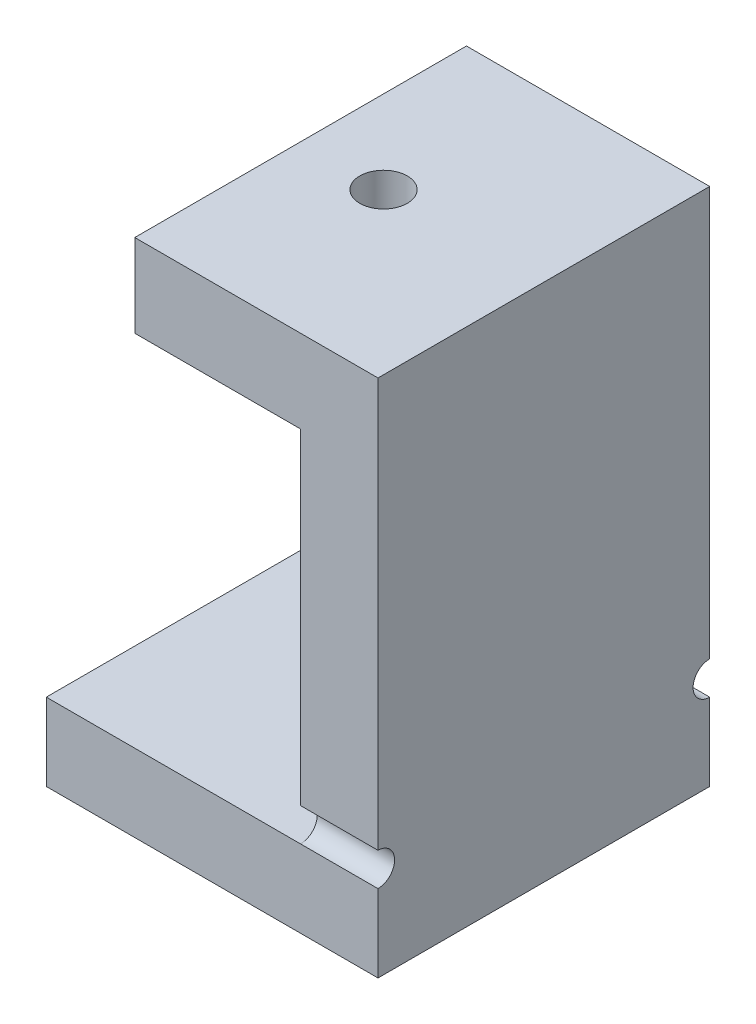
from build123d import *

# Parameters (mm, degrees)
SKETCH1_W                = 30
SKETCH1_H                = 30
BOSS_EXTRUDE1_DEPTH      = 7
SKETCH2_W                = 7
SKETCH2_H                = 30
BOSS_EXTRUDE2_DEPTH      = 40
SKETCH3_W                = 30
SKETCH3_H                = 7.5
BOSS_EXTRUDE3_DEPTH      = 15
CUT_EXTRUDE1_DEPTH       = 2.5
M4_CLEARANCE_HOLE1_D     = 4.3
M4_CLEARANCE_HOLE1_DEPTH = 6
M4_CLEARANCE_HOLE1_TIP   = 1.291850331
CUT_EXTRUDE3_DEPTH       = 13


with BuildPart() as part:
    # Sketch1 → Boss-Extrude1 (new body)
    with BuildSketch(Plane(origin=(0, 0, 0), x_dir=(1, 0, 0), z_dir=(0, 1, 0))):
        Rectangle(SKETCH1_W, SKETCH1_H)
    extrude(amount=BOSS_EXTRUDE1_DEPTH)

    # Sketch2 → Boss-Extrude2 (add)
    with BuildSketch(Plane(origin=(0, 7, 0), x_dir=(1, 0, 0), z_dir=(0, 1, 0))):
        with Locations((11.5, 0)):
            Rectangle(SKETCH2_W, SKETCH2_H)
    extrude(amount=BOSS_EXTRUDE2_DEPTH)

    # Sketch3 → Boss-Extrude3 (add)
    with BuildSketch(Plane.ZY.offset(-8)):
        with Locations((0, 43.25)):
            Rectangle(SKETCH3_W, SKETCH3_H)
    extrude(amount=BOSS_EXTRUDE3_DEPTH)

    # Sketch4 → Cut-Extrude1 (cut)
    with BuildSketch(Plane.XZ.offset(-39.5)):
        Polygon((0.5, -4.330127019), (4.25, -2.165063509), (4.25, 2.165063509), (0.5, 4.330127019), (-3.25, 2.165063509), (-3.25, -2.165063509), align=None)
    extrude(amount=-CUT_EXTRUDE1_DEPTH, mode=Mode.SUBTRACT)

    # M4 Clearance Hole1
    with Locations(Plane(origin=(0, 47, 0), x_dir=(-1, 0, 0), z_dir=(0, 1, 0))):
        with Locations((-0.5, 0)):
            Hole(M4_CLEARANCE_HOLE1_D / 2, depth=M4_CLEARANCE_HOLE1_DEPTH)
            with Locations((0, 0, -(M4_CLEARANCE_HOLE1_DEPTH + M4_CLEARANCE_HOLE1_TIP / 2))):  # 118° drill point
                Cone(0, M4_CLEARANCE_HOLE1_D / 2, M4_CLEARANCE_HOLE1_TIP, mode=Mode.SUBTRACT)

    # Sketch8 → Cut-Extrude3 (cut)
    with BuildSketch(Plane(origin=(15, 0, 0), x_dir=(0, 0, -1), z_dir=(1, 0, 0))):
        with BuildLine():
            Line((-15, 10), (-15, 7))
            ThreePointArc((-15, 7), (-13.5, 8.5), (-15, 10))
        make_face()
        with BuildLine():
            Line((15, 10), (15, 7))
            ThreePointArc((15, 7), (13.5, 8.5), (15, 10))
        make_face()
    extrude(amount=-CUT_EXTRUDE3_DEPTH, mode=Mode.SUBTRACT)


solid = part.part
